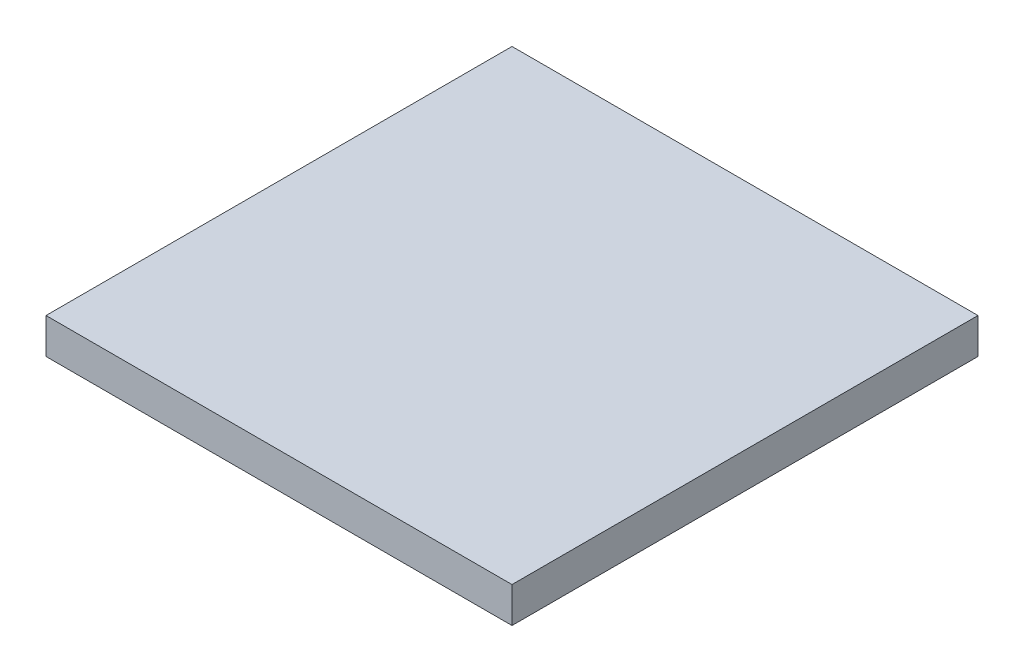
from build123d import *

# Parameters (mm, degrees)
SKETCH1_W           = 5
SKETCH1_H           = 5
BOSS_EXTRUDE1_DEPTH = 0.381


with BuildPart() as part:
    # Sketch1 → Boss-Extrude1 (new body)
    with BuildSketch(Plane(origin=(0, 0, 0), x_dir=(1, 0, 0), z_dir=(0, 1, 0))):
        with Locations((2.5, 2.5)):
            Rectangle(SKETCH1_W, SKETCH1_H)
    extrude(amount=BOSS_EXTRUDE1_DEPTH)


solid = part.part
